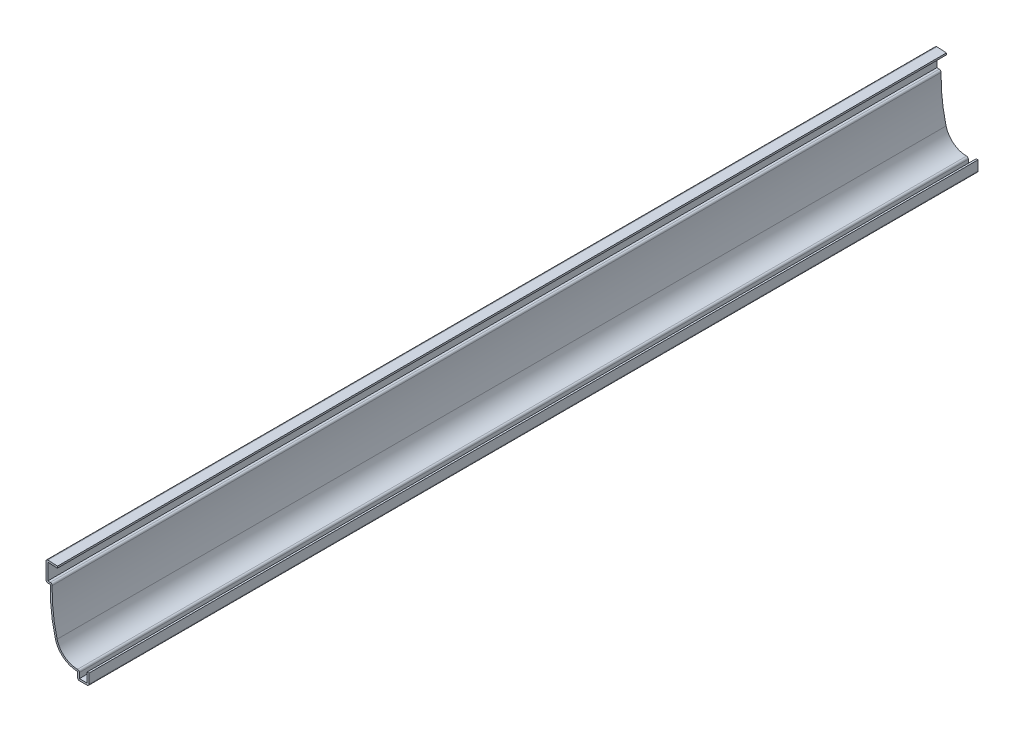
from build123d import *

# Parameters (mm, degrees)
EXTRUDE_THIN1_DEPTH = 492.125
FILLET1_R           = 1.016


with BuildPart() as part:
    # Sketch1 → Extrude-Thin1 (new body)
    with BuildSketch(Plane.XY):
        with BuildLine():
            Line((0, 6.35), (0, 0))
            Line((0, 0), (-6.35, 0))
            Line((-6.35, 0), (-6.35, 3.96875))
            ThreePointArc((-6.35, 3.96875), (-14.128687, 6.629724), (-18.647706, 13.497563))
            ThreePointArc((-18.647706, 13.497563), (-20.900169, 25.701402), (-21.43125, 38.1))
            Line((-21.43125, 38.1), (-23.8125, 38.1))
            Line((-23.8125, 38.1), (-23.8125, 49.2125))
            Line((-23.8125, 49.2125), (-17.4625, 48.879711))
            Line((-17.4625, 48.879711), (-17.515673, 47.865103))
            Line((-17.515673, 47.865103), (-22.7965, 48.141859))
            Line((-22.7965, 48.141859), (-22.7965, 39.116))
            Line((-22.7965, 39.116), (-20.381189, 39.116))
            ThreePointArc((-20.381189, 39.116), (-19.947758, 26.334511), (-17.66389, 13.751258))
            ThreePointArc((-17.66389, 13.751258), (-13.09767, 7.130154), (-5.334, 5.029008))
            Line((-5.334, 5.029008), (-5.334, 1.016))
            Line((-5.334, 1.016), (-1.016, 1.016))
            Line((-1.016, 1.016), (-1.016, 6.35))
            Line((-1.016, 6.35), (0, 6.35))
        make_face()
    extrude(amount=-EXTRUDE_THIN1_DEPTH)

    # Fillet1
    fillet1_edges = [part.edges().sort_by_distance(p)[0] for p in [
        (-20.381189, 39.116, -246.0625),
        (-5.334, 5.029008, -246.0625),
        (0, 0, -246.0625),
        (-6.35, 0, -246.0625),
        (-23.8125, 38.1, -246.0625),
        (-23.8125, 49.2125, -246.0625),
    ]]
    fillet(fillet1_edges, radius=FILLET1_R)


solid = part.part
